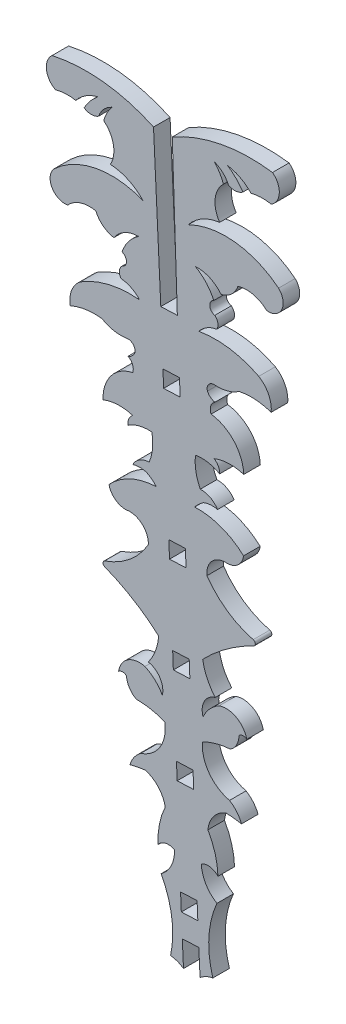
from build123d import *

# Parameters (mm, degrees)
BOSS_EXTRUDE1_DEPTH = 1.524
CUT_EXTRUDE1_DEPTH  = 1.524


with BuildPart() as part:
    # Sketch1 → Boss-Extrude1 (new body)
    with BuildSketch(Plane.XY):
        with BuildLine():
            Line((104.099354147, 66.085176728), (104.770113722, 52.102785281))
            Line((104.770113722, 52.102785281), (106.292896413, 52.164694321))
            Line((106.292896413, 52.164694321), (105.826404439, 66.155390309))
            ThreePointArc((105.826404439, 66.155390309), (110.293391455, 67.812038518), (115.055987235, 67.939072875))
            ThreePointArc((115.055987235, 67.939072875), (115.680933104, 66.615608969), (114.944393207, 65.350846924))
            ThreePointArc((114.944393207, 65.350846924), (114.008219051, 65.427766823), (113.079247965, 65.288657359))
            ThreePointArc((113.079247965, 65.288657359), (112.097204724, 66.037880041), (110.923823761, 66.423782445))
            ThreePointArc((110.923823761, 66.423782445), (111.699804375, 65.791967815), (112.32900836, 65.013868857))
            ThreePointArc((112.32900836, 65.013868857), (111.681326054, 64.764015459), (111.001749214, 64.905770207))
            ThreePointArc((111.001749214, 64.905770207), (110.467300629, 65.651696565), (109.682397564, 66.127058112))
            ThreePointArc((109.682397564, 66.127058112), (110.183018991, 65.484189249), (110.540573962, 64.752030366))
            ThreePointArc((110.540573962, 64.752030366), (109.773505554, 63.204794061), (110.188549248, 61.528466868))
            ThreePointArc((110.188549248, 61.528466868), (108.588235007, 60.996504709), (107.306756612, 59.900237162))
            ThreePointArc((107.306756612, 59.900237162), (111.592674916, 60.661149878), (115.61528283, 58.997807031))
            ThreePointArc((115.61528283, 58.997807031), (115.910495787, 57.437411657), (114.526121794, 56.659277312))
            ThreePointArc((114.526121794, 56.659277312), (113.279596637, 57.321626865), (111.869058048, 57.267656618))
            ThreePointArc((111.869058048, 57.267656618), (111.282167886, 56.357080446), (110.327643064, 55.844760829))
            ThreePointArc((110.327643064, 55.844760829), (109.273614929, 56.65900436), (107.961632761, 56.888505182))
            ThreePointArc((107.961632761, 56.888505182), (108.956858884, 56.094004999), (109.645040248, 55.022505122))
            ThreePointArc((109.645040248, 55.022505122), (109.280500714, 54.42146977), (109.737493459, 53.887344133))
            ThreePointArc((109.737493459, 53.887344133), (110.024177522, 53.411769858), (109.912783771, 52.867756921))
            ThreePointArc((109.912783771, 52.867756921), (108.999050351, 52.530131203), (108.272951495, 51.880762018))
            ThreePointArc((108.272951495, 51.880762018), (111.099562226, 51.919154451), (113.790210447, 51.052197501))
            ThreePointArc((113.790210447, 51.052197501), (114.691895814, 50.066530961), (114.933056289, 48.752599208))
            ThreePointArc((114.933056289, 48.752599208), (113.477937267, 49.049334116), (111.996421657, 48.946696547))
            ThreePointArc((111.996421657, 48.946696547), (110.938671768, 48.450736989), (109.776407554, 48.33261584))
            ThreePointArc((109.776407554, 48.33261584), (109.192861561, 48.114599464), (109.063721626, 47.50518996))
            ThreePointArc((109.063721626, 47.50518996), (109.342559273, 47.156511006), (109.742866855, 46.958821132))
            ThreePointArc((109.742866855, 46.958821132), (109.362116727, 46.465676566), (109.403181351, 45.844004691))
            ThreePointArc((109.403181351, 45.844004691), (111.50888673, 44.737710963), (112.407866495, 42.535503812))
            ThreePointArc((112.407866495, 42.535503812), (111.035598057, 42.717973395), (109.681047689, 42.432300301))
            ThreePointArc((109.681047689, 42.432300301), (110.068540178, 42.021650019), (110.189884946, 41.470234086))
            ThreePointArc((110.189884946, 41.470234086), (109.109191511, 41.854551347), (107.96220492, 41.850099498))
            ThreePointArc((107.96220492, 41.850099498), (107.997898267, 40.571223966), (108.406916398, 39.35899428))
            ThreePointArc((108.406916398, 39.35899428), (109.313595088, 39.15965102), (109.998617021, 38.533113764))
            ThreePointArc((109.998617021, 38.533113764), (109.335596821, 38.582396151), (108.689289384, 38.426475546))
            ThreePointArc((108.689289384, 38.426475546), (108.255677128, 38.084129636), (107.882559047, 37.676694723))
            ThreePointArc((107.882559047, 37.676694723), (110.30231795, 37.308049976), (112.3932049, 36.035523412))
            ThreePointArc((112.3932049, 36.035523412), (111.805823979, 35.00782104), (110.665565804, 34.690016373))
            ThreePointArc((110.665565804, 34.690016373), (109.423848414, 34.088679123), (109.0205809, 32.769268696))
            ThreePointArc((109.0205809, 32.769268696), (110.881198196, 30.897808998), (113.279971571, 29.797743355))
            ThreePointArc((113.279971571, 29.797743355), (113.469624985, 29.577406885), (113.328245716, 29.32338232))
            ThreePointArc((113.328245716, 29.32338232), (110.825611522, 27.817625119), (108.62526435, 25.896959875))
            ThreePointArc((108.62526435, 25.896959875), (109.034185855, 24.588407396), (109.78053286, 23.438410641))
            ThreePointArc((109.78053286, 23.438410641), (108.772083233, 22.622569281), (108.66244401, 21.330072854))
            ThreePointArc((108.66244401, 21.330072854), (109.269259447, 22.262733067), (110.143284435, 22.951326102))
            ThreePointArc((110.143284435, 22.951326102), (111.73057647, 22.820498677), (112.685444589, 21.545807069))
            ThreePointArc((112.685444589, 21.545807069), (112.31217066, 21.66345127), (111.962852961, 21.486955578))
            ThreePointArc((111.962852961, 21.486955578), (111.758710405, 20.652571259), (111.181577573, 20.016340901))
            ThreePointArc((111.181577573, 20.016340901), (109.857237138, 19.787872945), (108.600968666, 19.31052117))
            ThreePointArc((108.600968666, 19.31052117), (109.214689622, 17.134741161), (111.099233498, 15.886075297))
            ThreePointArc((111.099233498, 15.886075297), (111.759447532, 15.317014544), (112.204368843, 14.567509548))
            ThreePointArc((112.204368843, 14.567509548), (111.487719307, 14.669325353), (110.765730095, 14.721138435))
            ThreePointArc((110.765730095, 14.721138435), (109.627733648, 13.869316691), (109.10941437, 12.545692378))
            ThreePointArc((109.10941437, 12.545692378), (109.774010553, 10.982160127), (110.035017226, 9.303411574))
            ThreePointArc((110.035017226, 9.303411574), (109.306326432, 9.688124883), (108.497824326, 9.529005595))
            ThreePointArc((108.497824326, 9.529005595), (108.912879298, 8.132688946), (109.937136194, 7.096895228))
            ThreePointArc((109.937136194, 7.096895228), (109.198396304, 4.060042403), (109.563030275, 0.955971887))
            ThreePointArc((109.563030275, 0.955971887), (108.711468988, 0.635293614), (108.031192171, 0.030963713))
            Line((108.031192171, 0.030963713), (107.651012863, 0))
            Line((107.651012863, 0), (107.26957472, 0))
            ThreePointArc((107.26957472, 0), (106.542485751, 0.54711316), (105.667703363, 0.797606579))
            ThreePointArc((105.667703363, 0.797606579), (105.779157198, 3.921032542), (104.796335045, 6.887894911))
            ThreePointArc((104.796335045, 6.887894911), (105.733129817, 8.003415584), (106.033467281, 9.428816658))
            ThreePointArc((106.033467281, 9.428816658), (105.214716718, 9.521779658), (104.519660354, 9.079183619))
            ThreePointArc((104.519660354, 9.079183619), (104.643531156, 10.773579443), (105.179012353, 12.385901084))
            ThreePointArc((105.179012353, 12.385901084), (104.554956812, 13.663081917), (103.351568341, 14.419714181))
            ThreePointArc((103.351568341, 14.419714181), (102.636167855, 14.309463729), (101.930148455, 14.149809028))
            ThreePointArc((101.930148455, 14.149809028), (102.312759427, 14.932957517), (102.92460039, 15.553733925))
            ThreePointArc((102.92460039, 15.553733925), (104.701562831, 16.951259073), (105.136636734, 19.16967805))
            ThreePointArc((105.136636734, 19.16967805), (103.845764624, 19.543475308), (102.507248658, 19.663684294))
            ThreePointArc((102.507248658, 19.663684294), (101.880373715, 20.250965472), (101.6091727, 21.066024601))
            ThreePointArc((101.6091727, 21.066024601), (101.246680577, 21.21358152), (100.884188453, 21.066024601))
            ThreePointArc((100.884188453, 21.066024601), (101.732430616, 22.414022024), (103.303864134, 22.673268079))
            ThreePointArc((103.303864134, 22.673268079), (104.230902023, 22.057897621), (104.91142467, 21.177574399))
            ThreePointArc((104.91142467, 21.177574399), (104.697227289, 22.456905184), (103.625878854, 23.188191931))
            ThreePointArc((103.625878854, 23.188191931), (104.276410331, 24.394979064), (104.577758935, 25.732407719))
            ThreePointArc((104.577758935, 25.732407719), (102.228761046, 27.468118418), (99.612154427, 28.765751844))
            ThreePointArc((99.612154427, 28.765751844), (99.450620985, 29.007461431), (99.621762413, 29.242466089))
            ThreePointArc((99.621762413, 29.242466089), (101.923320083, 30.533624644), (103.625878851, 32.549945988))
            ThreePointArc((103.625878851, 32.549945988), (103.116837445, 33.832266312), (101.830403723, 34.330821064))
            ThreePointArc((101.830403723, 34.330821064), (100.668110484, 34.555015037), (99.999243049, 35.531644376))
            ThreePointArc((99.999243049, 35.531644376), (101.979930665, 36.969701631), (104.361778599, 37.533556679))
            ThreePointArc((104.361778599, 37.533556679), (103.956817864, 37.909358639), (103.496846279, 38.215375717))
            ThreePointArc((103.496846279, 38.215375717), (102.840014761, 38.318316943), (102.183183243, 38.215375716))
            ThreePointArc((102.183183243, 38.215375716), (102.815084507, 38.895452753), (103.702589008, 39.167738895))
            ThreePointArc((103.702589008, 39.167738895), (104.011853041, 40.409170487), (103.943614292, 41.68672288))
            ThreePointArc((103.943614292, 41.68672288), (102.800051644, 41.598051984), (101.754122181, 41.127276437))
            ThreePointArc((101.754122181, 41.127276437), (101.830304613, 41.686722879), (102.183183242, 42.1274731))
            ThreePointArc((102.183183242, 42.1274731), (100.809913344, 42.302246106), (99.45698591, 42.008983132))
            ThreePointArc((99.45698591, 42.008983132), (100.174231946, 44.276898271), (102.18318324, 45.550474202))
            ThreePointArc((102.18318324, 45.550474202), (102.17364736, 46.173427884), (101.754122179, 46.634037095))
            ThreePointArc((101.754122179, 46.634037095), (102.137060932, 46.863570007), (102.386673904, 47.233733229))
            ThreePointArc((102.386673904, 47.233733229), (102.208490593, 47.830648444), (101.609172691, 48.000575248))
            ThreePointArc((101.609172691, 48.000575248), (100.441155593, 48.023958337), (99.3466364, 48.432416959))
            ThreePointArc((99.3466364, 48.432416959), (97.86167841, 48.414451941), (96.435449447, 48.000575246))
            ThreePointArc((96.435449447, 48.000575246), (96.569154003, 49.329747214), (97.387850898, 50.385356243))
            ThreePointArc((97.387850898, 50.385356243), (99.999243043, 51.467868721), (102.819641844, 51.659056606))
            ThreePointArc((102.819641844, 51.659056606), (102.043225941, 52.247340749), (101.105100873, 52.509678784))
            ThreePointArc((101.105100873, 52.509678784), (100.949913826, 53.042853824), (101.197046435, 53.540130525))
            ThreePointArc((101.197046435, 53.540130525), (101.609172688, 54.109590372), (101.197046434, 54.679050218))
            ThreePointArc((101.197046434, 54.679050218), (101.795976312, 55.802877864), (102.723423421, 56.675544717))
            ThreePointArc((102.723423421, 56.675544717), (101.434401117, 56.34029953), (100.449948748, 55.443181161))
            ThreePointArc((100.449948748, 55.443181161), (99.456985905, 55.876325272), (98.798115475, 56.736254794))
            ThreePointArc((98.798115475, 56.736254794), (97.387850895, 56.675544715), (96.199206608, 55.914192854))
            ThreePointArc((96.199206608, 55.914192854), (94.756235361, 56.577380905), (94.923807025, 58.156590881))
            ThreePointArc((94.923807025, 58.156590881), (98.798115474, 60.140984466), (103.131657263, 59.73049765))
            ThreePointArc((103.131657263, 59.73049765), (101.765417179, 60.719121665), (100.127201668, 61.119420739))
            ThreePointArc((100.127201668, 61.119420739), (100.404797691, 62.823907341), (99.514661973, 64.303769676))
            ThreePointArc((99.514661973, 64.303769676), (99.811603028, 65.062537227), (100.258386612, 65.743923033))
            ThreePointArc((100.258386612, 65.743923033), (99.514661973, 65.206414817), (99.042528687, 64.419565669))
            ThreePointArc((99.042528687, 64.419565669), (98.376701728, 64.223113255), (97.710874768, 64.419565668))
            ThreePointArc((97.710874768, 64.419565668), (98.274839088, 65.246173125), (98.996970451, 65.938893802))
            ThreePointArc((98.996970451, 65.938893802), (97.858788026, 65.459014319), (96.940804836, 64.632545677))
            ThreePointArc((96.940804836, 64.632545677), (96.003607191, 64.695785673), (95.076766699, 64.543124534))
            ThreePointArc((95.076766699, 64.543124534), (94.239988938, 65.743923031), (94.755438521, 67.113749946))
            ThreePointArc((94.755438521, 67.113749946), (99.512628781, 67.373744422), (104.099354147, 66.085176728))
        make_face()
        Polygon((105.51073373, 33.886182928), (107.033475822, 33.948090317), (107.095383212, 32.425348227), (105.572641119, 32.363440837), align=None, mode=Mode.SUBTRACT)
        Polygon((107.737696957, 16.626294454), (107.799604347, 15.103552364), (106.276862254, 15.041644974), (106.214954865, 16.564387065), align=None, mode=Mode.SUBTRACT)
        Polygon((104.968086356, 47.23373323), (106.490828449, 47.29564062), (106.552735838, 45.772898529), (105.029993746, 45.710991139), align=None, mode=Mode.SUBTRACT)
        Polygon((105.924751687, 23.702542906), (107.447493778, 23.764450295), (107.385586389, 25.287192386), (105.862844298, 25.225284996), align=None, mode=Mode.SUBTRACT)
    extrude(amount=BOSS_EXTRUDE1_DEPTH)

    # Sketch2 → Cut-Extrude1 (cut)
    with BuildSketch(Plane.XY.offset(1.524)):
        Polygon((108.422170972, -0.383298411), (108.270853858, 2.748588093), (106.748629516, 2.675041815), (106.899946631, -0.456844689), align=None)
        Polygon((106.589464588, 6.335646314), (106.657558358, 4.769482965), (108.180119956, 4.835681015), (108.112026185, 6.401844364), align=None)
    extrude(amount=-CUT_EXTRUDE1_DEPTH, mode=Mode.SUBTRACT)


solid = part.part
